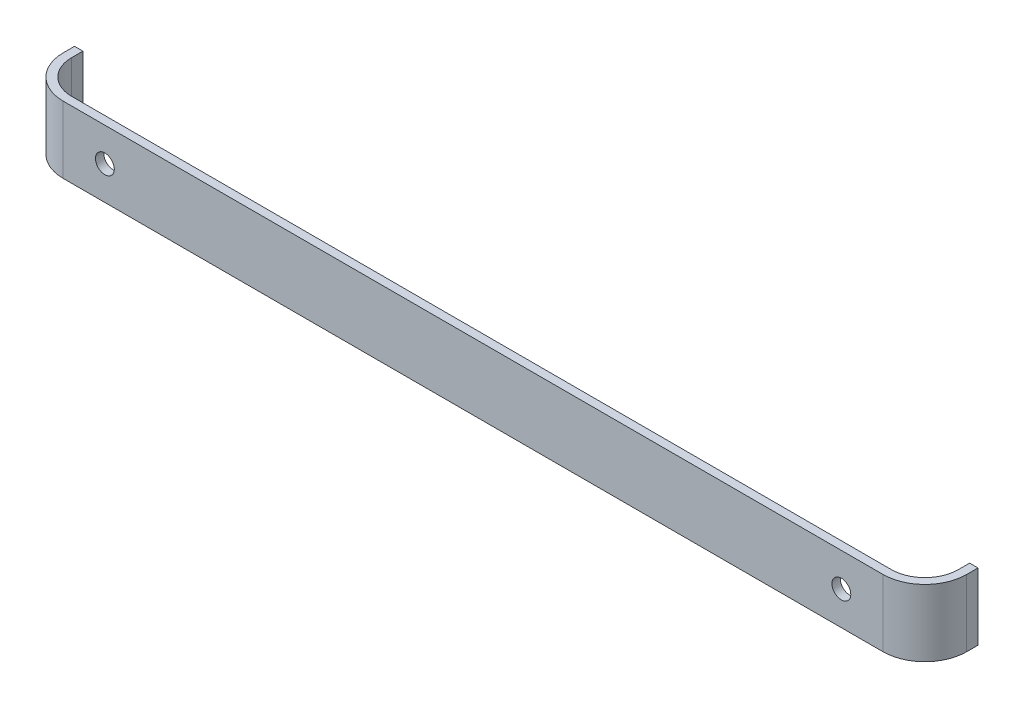
from build123d import *

# Parameters (mm, degrees)
BOSS_EXTRUDE1_DEPTH = 16
FILLET1_R           = 8
FILLET2_R           = 10
SKETCH2_R           = 2.25
CUT_EXTRUDE1_DEPTH  = 13.7


with BuildPart() as part:
    # Sketch1 → Boss-Extrude1 (new body)
    with BuildSketch(Plane(origin=(0, 0, 0), x_dir=(1, 0, 0), z_dir=(0, 1, 0))):
        Polygon((0, 0), (211.9, 0), (211.9, 10.7), (213.9, 10.7), (213.9, -2), (-2, -2), (-2, 10.7), (0, 10.7), align=None)
    extrude(amount=BOSS_EXTRUDE1_DEPTH)

    # Fillet1
    fillet1_edges = [part.edges().sort_by_distance(p)[0] for p in [
        (0, 8, 0),
        (211.9, 8, 0),
    ]]
    fillet(fillet1_edges, radius=FILLET1_R)

    # Fillet2
    fillet2_edges = [part.edges().sort_by_distance(p)[0] for p in [
        (213.9, 8, 2),
        (-2, 8, 2),
    ]]
    fillet(fillet2_edges, radius=FILLET2_R)

    # Sketch2 → Cut-Extrude1 (cut, through all)
    with BuildSketch(Plane.XY.offset(2)):
        with Locations((17.95, 8)):
            Circle(SKETCH2_R)
        with Locations((193.95, 8)):
            Circle(SKETCH2_R)
    extrude(amount=-CUT_EXTRUDE1_DEPTH, mode=Mode.SUBTRACT)


solid = part.part
